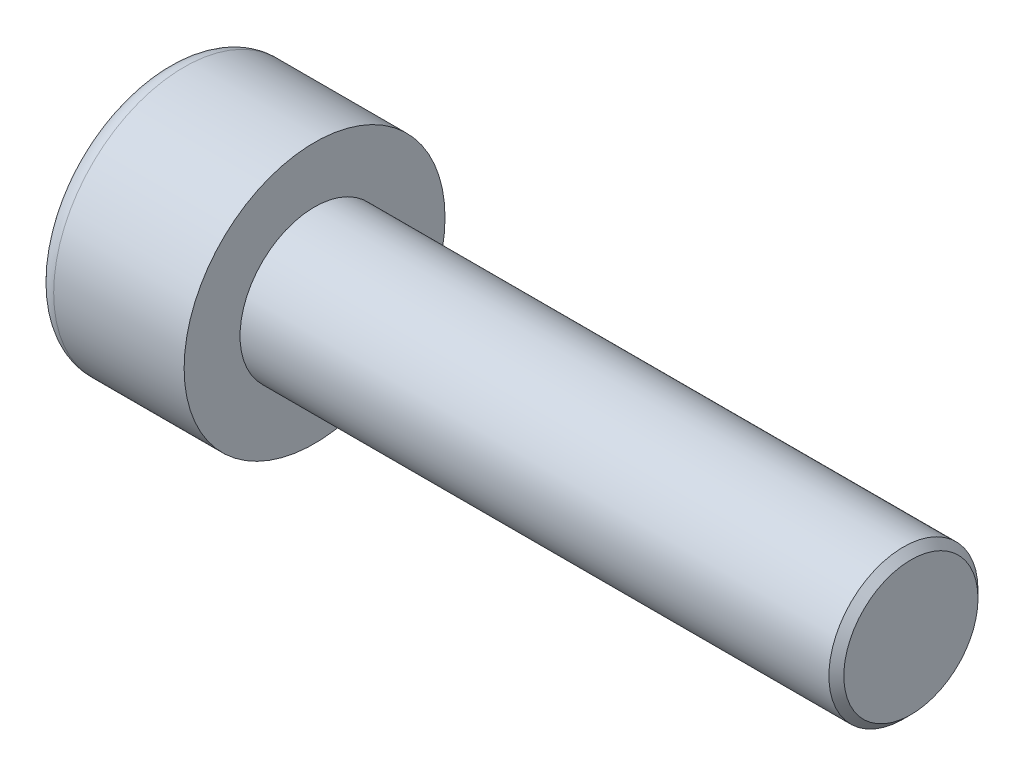
from build123d import *

# Parameters (mm, degrees)
SKETCH1_R           = 3.5
BASEHEAD_DEPTH      = 4
SKETCH2_R           = 2
BASEBODY_DEPTH      = 16
HEXAGONSOCKET_DEPTH = 2
TOPFILLET_R         = 0.5
CHAMFER1_SIZE       = 0.2


with BuildPart() as part:
    # Sketch1 → BaseHead (new body)
    with BuildSketch(Plane(origin=(0, 0, 0), x_dir=(0, 0, -1), z_dir=(1, 0, 0))):
        Circle(SKETCH1_R)
    extrude(amount=BASEHEAD_DEPTH)

    # Sketch2 → BaseBody (add)
    with BuildSketch(Plane(origin=(4, 0, 0), x_dir=(0, 0, -1), z_dir=(1, 0, 0))):
        Circle(SKETCH2_R)
    extrude(amount=BASEBODY_DEPTH)

    # Sketch3 → HexagonSocket (cut)
    with BuildSketch(Plane(origin=(0, 0, 0), x_dir=(0, 0, -1), z_dir=(1, 0, 0))):
        Polygon((1.732050808, 0), (0.866025404, 1.5), (-0.866025404, 1.5), (-1.732050808, 0), (-0.866025404, -1.5), (0.866025404, -1.5), align=None)
    extrude(amount=HEXAGONSOCKET_DEPTH, mode=Mode.SUBTRACT)

    # Sketch4 → Cut-Revolve1 (revolve, cut)
    with BuildSketch(Plane(origin=(-4.19613823, 0.75, 0), x_dir=(-1, 0, 0), z_dir=(0, 0, 1))):
        Polygon((-6.19613823, 2.25), (-7.062163633, 0.75), (-6.19613823, 0.75), align=None)
    revolve(axis=Axis((0.838992387, 0, 0), (-1, 0, 0)), mode=Mode.SUBTRACT)

    # TopFillet
    topfillet_edges = [part.edges().sort_by_distance(p)[0] for p in [
        (0, 0, 3.5),
    ]]
    fillet(topfillet_edges, radius=TOPFILLET_R)

    # Chamfer1
    chamfer1_edges = [part.edges().sort_by_distance(p)[0] for p in [
        (20, 0, 2),
    ]]
    chamfer(chamfer1_edges, length=CHAMFER1_SIZE)


solid = part.part
